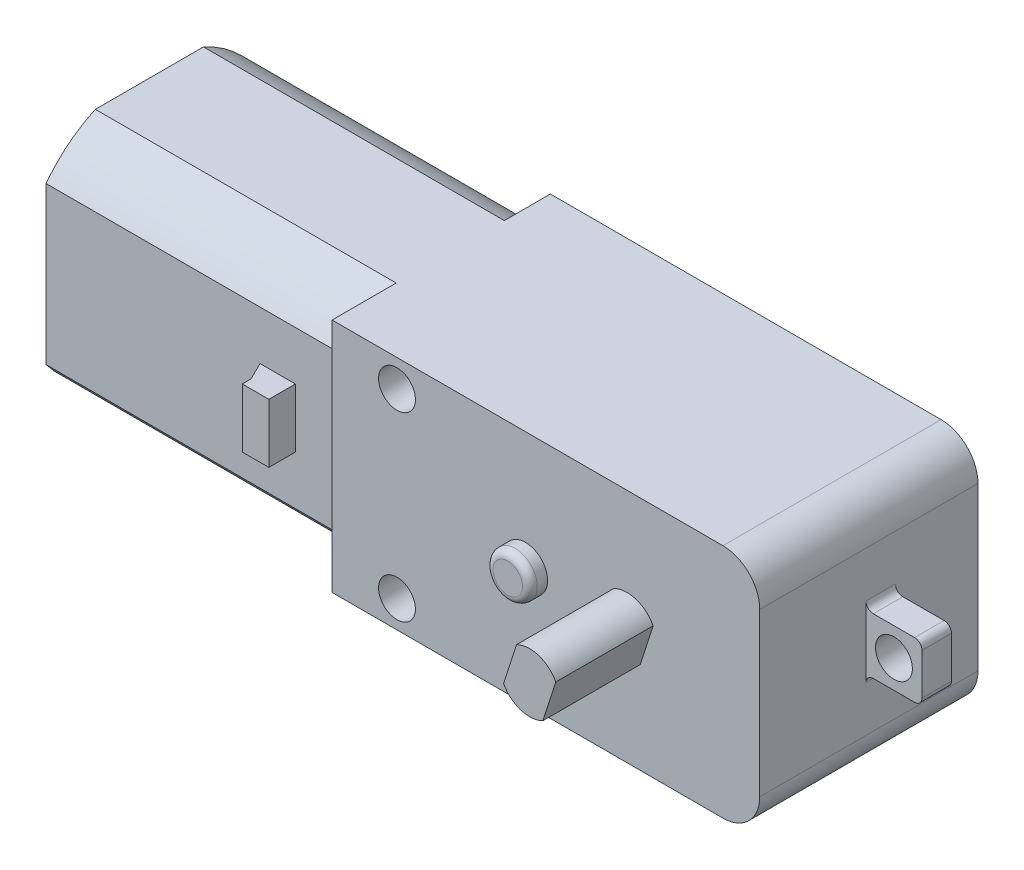
from build123d import *

# Parameters (mm, degrees)
SKETCH1_W           = 36.83
SKETCH1_H           = 20.32
BOSS_EXTRUDE1_DEPTH = 18.796
FILLET1_R           = 3.175
BOSS_EXTRUDE2_DEPTH = 25.908
BOSS_EXTRUDE3_DEPTH = 8.382
SKETCH4_R           = 1.5875
CUT_EXTRUDE1_DEPTH  = 43.578916332
BOSS_EXTRUDE4_START = -7.112
SKETCH5_W           = 4.826
SKETCH5_H           = 4.826
SKETCH5_R           = 1.5875
BOSS_EXTRUDE4_DEPTH = 2.54
FILLET2_R           = 0.635
BOSS_EXTRUDE5_DEPTH = 2.54
BOSS_EXTRUDE6_DEPTH = 4.064
FILLET3_R           = 1.27
SKETCH8_R           = 1.905
BOSS_EXTRUDE7_DEPTH = 1.524
FILLET4_R           = 0.635


with BuildPart() as part:
    # Sketch1 → Boss-Extrude1 (new body)
    with BuildSketch(Plane.XY):
        with Locations((18.415, 0)):
            Rectangle(SKETCH1_W, SKETCH1_H)
    extrude(amount=BOSS_EXTRUDE1_DEPTH)

    # Fillet1
    fillet1_edges = [part.edges().sort_by_distance(p)[0] for p in [
        (36.83, 10.16, 9.398),
        (36.83, -10.16, 9.398),
    ]]
    fillet(fillet1_edges, radius=FILLET1_R)

    # Sketch2 → Boss-Extrude2 (add)
    with BuildSketch(Plane.ZY):
        with BuildLine():
            ThreePointArc((3.96514897, 10.16), (1.809887501, 8.860648824), (0, 7.112))
            Line((0, 7.112), (0, -7.112))
            ThreePointArc((0, -7.112), (1.809887501, -8.860648824), (3.96514897, -10.16))
            Line((3.96514897, -10.16), (13.276942782, -10.16))
            ThreePointArc((13.276942782, -10.16), (15.61217315, -8.719352926), (17.526, -6.753130241))
            Line((17.526, -6.753130241), (17.526, 6.753130241))
            ThreePointArc((17.526, 6.753130241), (15.61217315, 8.719352926), (13.276942782, 10.16))
            Line((13.276942782, 10.16), (3.96514897, 10.16))
        make_face()
    extrude(amount=BOSS_EXTRUDE2_DEPTH)

    # Sketch3 → Boss-Extrude3 (add)
    with BuildSketch(Plane.XY.offset(18.796)):
        with BuildLine():
            Line((24.267261803, 2.273434446), (23.149675051, -1.177980315))
            ThreePointArc((23.149675051, -1.177980315), (24.617532764, -2.416473676), (26.532738197, -2.273434446))
            Line((26.532738197, -2.273434446), (27.650324949, 1.177980315))
            ThreePointArc((27.650324949, 1.177980315), (26.182467236, 2.416473676), (24.267261803, 2.273434446))
        make_face()
    extrude(amount=BOSS_EXTRUDE3_DEPTH)

    # Sketch4 → Cut-Extrude1 (cut, through all)
    with BuildSketch(Plane.XY.offset(18.796)):
        with Locations((5.588, 7.8105)):
            Circle(SKETCH4_R)
        with Locations((5.588, -7.8105)):
            Circle(SKETCH4_R)
    extrude(amount=-CUT_EXTRUDE1_DEPTH, mode=Mode.SUBTRACT)

    # Sketch5 → Boss-Extrude4 (add)
    with BuildSketch(Plane(origin=(0, 0, 0), x_dir=(-1, 0, 0), z_dir=(0, 0, -1)).offset(BOSS_EXTRUDE4_START)):
        with Locations((-39.243, 0)):
            Rectangle(SKETCH5_W, SKETCH5_H)
        with Locations((-39.243, 0)):
            Circle(SKETCH5_R, mode=Mode.SUBTRACT)
    extrude(amount=-BOSS_EXTRUDE4_DEPTH)

    # Fillet2
    fillet2_edges = [part.edges().sort_by_distance(p)[0] for p in [
        (36.83, 2.413, 8.382),
        (36.83, -2.413, 8.382),
        (41.656, 2.413, 8.382),
        (41.656, -2.413, 8.382),
    ]]
    fillet(fillet2_edges, radius=FILLET2_R)

    # Sketch6 → Boss-Extrude5 (add, symmetric)
    with BuildSketch(Plane(origin=(0, 0, 0), x_dir=(-1, 0, 0), z_dir=(0, -1, 0))):
        Polygon((4.430989114, -19.812), (6.716989114, -19.812), (6.716989114, -19.05), (7.478989114, -17.526), (4.430989114, -17.526), align=None)
        Polygon((6.716989114, 2.286), (6.716989114, 1.524), (7.478989114, 0), (4.430989114, 0), (4.430989114, 2.286), align=None)
    extrude(amount=BOSS_EXTRUDE5_DEPTH, both=True)

    # Sketch6_3 → Boss-Extrude6 (add, symmetric)
    with BuildSketch(Plane(origin=(0, 0, 0), x_dir=(-1, 0, 0), z_dir=(0, -1, 0))):
        Polygon((17.526, 0), (18.796, 1.27), (25.908, 1.27), (25.908, 0), align=None)
    extrude(amount=BOSS_EXTRUDE6_DEPTH, both=True)

    # Fillet3
    fillet3_edges = [part.edges().sort_by_distance(p)[0] for p in [
        (-25.908, 0, -1.27),
        (-18.796, 0, -1.27),
    ]]
    fillet(fillet3_edges, radius=FILLET3_R)

    # Sketch8 → Boss-Extrude7 (add)
    with BuildSketch(Plane.XY.offset(18.796)):
        with Locations((16.651010886, 0)):
            Circle(SKETCH8_R)
    extrude(amount=BOSS_EXTRUDE7_DEPTH)

    # Fillet4
    fillet4_edges = [part.edges().sort_by_distance(p)[0] for p in [
        (14.746010886, 0, 20.32),
    ]]
    fillet(fillet4_edges, radius=FILLET4_R)


solid = part.part
